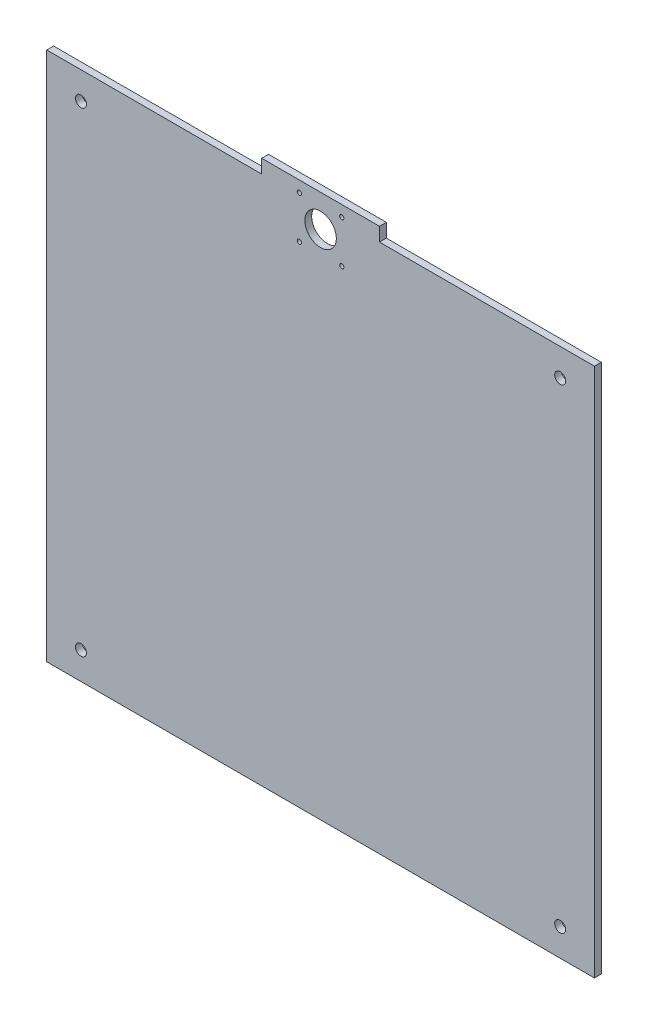
from build123d import *

# Parameters (mm, degrees)
SKETCH1_W           = 400
SKETCH1_H           = 397
BOSS_EXTRUDE1_DEPTH = 5
SKETCH2_R           = 1.55
CUT_EXTRUDE1_DEPTH  = 6
SKETCH3_R           = 11.5
CUT_EXTRUDE2_DEPTH  = 6
SKETCH4_W           = 157
SKETCH4_H           = 10
CUT_EXTRUDE3_DEPTH  = 6
SKETCH5_R           = 4
CUT_EXTRUDE4_DEPTH  = 5


with BuildPart() as part:
    # Sketch1 → Boss-Extrude1 (new body)
    with BuildSketch(Plane.XY):
        with Locations((200, 198.5)):
            Rectangle(SKETCH1_W, SKETCH1_H)
    extrude(amount=BOSS_EXTRUDE1_DEPTH)

    # Sketch2 → Cut-Extrude1 (cut, through all)
    with BuildSketch(Plane.XY.offset(5)):
        with Locations((215.5, 389)):
            Circle(SKETCH2_R)
        with Locations((215.5, 358)):
            Circle(SKETCH2_R)
        with Locations((184.5, 358)):
            Circle(SKETCH2_R)
        with Locations((184.5, 389)):
            Circle(SKETCH2_R)
    extrude(amount=-CUT_EXTRUDE1_DEPTH, mode=Mode.SUBTRACT)

    # Sketch3 → Cut-Extrude2 (cut, through all)
    with BuildSketch(Plane.XY.offset(5)):
        with Locations((200, 373.5)):
            Circle(SKETCH3_R)
    extrude(amount=-CUT_EXTRUDE2_DEPTH, mode=Mode.SUBTRACT)

    # Sketch4 → Cut-Extrude3 (cut, through all)
    with BuildSketch(Plane.XY.offset(5)):
        with Locations((321.5, 392)):
            Rectangle(SKETCH4_W, SKETCH4_H)
        with Locations((78.5, 392)):
            Rectangle(SKETCH4_W, SKETCH4_H)
    extrude(amount=-CUT_EXTRUDE3_DEPTH, mode=Mode.SUBTRACT)

    # Sketch5 → Cut-Extrude4 (cut)
    with BuildSketch(Plane.XY.offset(5)):
        with Locations((25, 367.03)):
            Circle(SKETCH5_R)
        with Locations((25, 20.03)):
            Circle(SKETCH5_R)
        with Locations((375, 20.03)):
            Circle(SKETCH5_R)
        with Locations((375, 367.03)):
            Circle(SKETCH5_R)
    extrude(amount=-CUT_EXTRUDE4_DEPTH, mode=Mode.SUBTRACT)


solid = part.part
